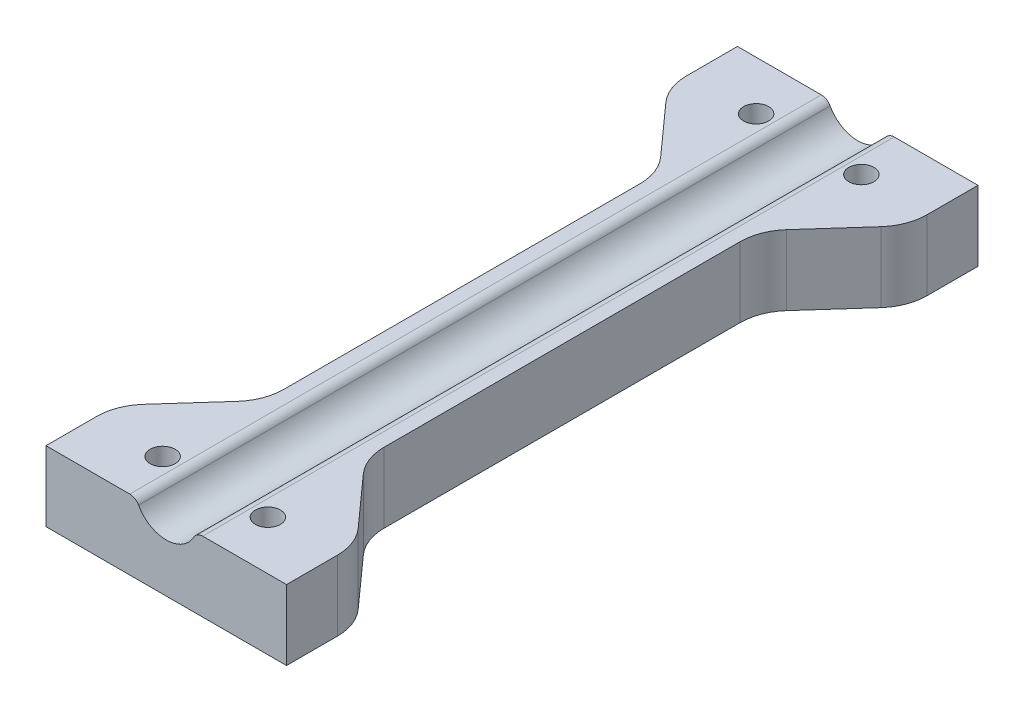
from build123d import *

# Parameters (mm, degrees)
BOSS_EXTRUDE1_DEPTH = 34.5
FILLET1_R           = 1
CUT_EXTRUDE1_DEPTH  = 8
FILLET2_R           = 5
SKETCH3_R           = 1.25
CUT_EXTRUDE2_DEPTH  = 8


with BuildPart() as part:
    # Sketch1 → Boss-Extrude1 (new body, symmetric)
    with BuildSketch(Plane.XY):
        with BuildLine():
            Line((-12, -1), (-2.987055406, -1))
            ThreePointArc((-2.987055406, -1), (0, -3.15), (2.987055406, -1))
            Line((2.987055406, -1), (12, -1))
            Line((12, -1), (12, -8))
            Line((12, -8), (-12, -8))
            Line((-12, -8), (-12, -1))
        make_face()
    extrude(amount=BOSS_EXTRUDE1_DEPTH, both=True)

    # Fillet1
    fillet1_edges = [part.edges().sort_by_distance(p)[0] for p in [
        (-2.987055406, -1, 0),
        (2.987055406, -1, 0),
    ]]
    fillet(fillet1_edges, radius=FILLET1_R)

    # Sketch2 → Cut-Extrude1 (cut, through all)
    with BuildSketch(Plane(origin=(0, -1, 0), x_dir=(1, 0, 0), z_dir=(0, 1, 0))):
        Polygon((-12, 27.5), (-5, 19.686646885), (-5, -19.686646885), (-12, -27.5), align=None)
        Polygon((12, -27.5), (5, -19.686646885), (5, 19.686646885), (12, 27.5), align=None)
    extrude(amount=-CUT_EXTRUDE1_DEPTH, mode=Mode.SUBTRACT)

    # Fillet2
    fillet2_edges = [part.edges().sort_by_distance(p)[0] for p in [
        (-12, -4.5, 27.5),
        (-12, -4.5, -27.5),
        (-5, -4.5, -19.686646885),
        (-5, -4.5, 19.686646885),
        (12, -4.5, -27.5),
        (12, -4.5, 27.5),
        (5, -4.5, 19.686646885),
        (5, -4.5, -19.686646885),
    ]]
    fillet(fillet2_edges, radius=FILLET2_R)

    # Sketch3 → Cut-Extrude2 (cut, through all)
    with BuildSketch(Plane(origin=(0, -1, 0), x_dir=(1, 0, 0), z_dir=(0, 1, 0))):
        with Locations((5.25, 29.610191819)):
            Circle(SKETCH3_R)
        with Locations((-5.25, 29.610191819)):
            Circle(SKETCH3_R)
        with Locations((-5.25, -29.610191819)):
            Circle(SKETCH3_R)
        with Locations((5.25, -29.610191819)):
            Circle(SKETCH3_R)
    extrude(amount=-CUT_EXTRUDE2_DEPTH, mode=Mode.SUBTRACT)


solid = part.part
